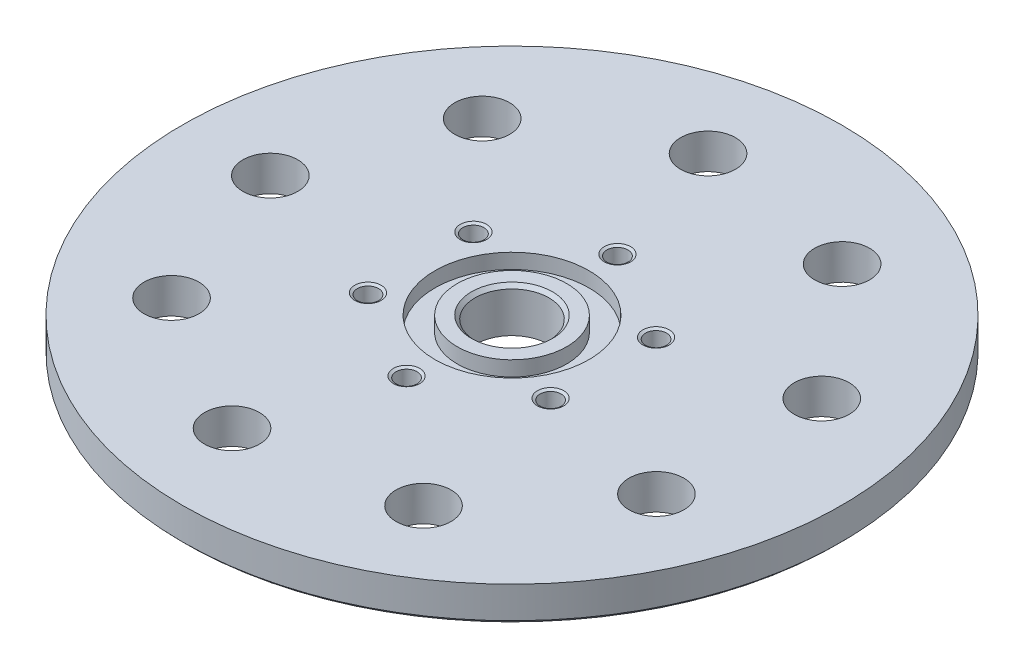
from build123d import *

# Parameters (mm, degrees)
SKETCH1_W               = 127
SKETCH1_H               = 127
BOSS_EXTRUDE1_DEPTH     = 5.08
CUT_EXTRUDE1_REACH      = 91.946
SKETCH2_R               = 5.3467
SKETCH4_R               = 11.1379
SKETCH4_R_2             = 7.9121
CUT_EXTRUDE3_DEPTH      = 2.159
CUT_EXTRUDE5_REACH      = 91.946
SKETCH6_R               = 3.96875
CIRPATTERN2_COUNT       = 9
CUT_EXTRUDE6_REACH      = 91.946
SKETCH7_R               = 3.175
SKETCH9_R               = 19.05
SKETCH9_R_2             = 5.3467
BOSS_EXTRUDE2_DEPTH     = 1.27
CUT_EXTRUDE7_DEPTH      = 91.02678768
CUT_EXTRUDE7_DEPTH_BACK = 91.02678768
SKETCH10_W              = 168.716053106
SKETCH10_H              = 169.87414825
SKETCH10_R              = 47.625
SKETCH16_R              = 19.05
SKETCH16_R_2            = 10.9855
BOSS_EXTRUDE3_DEPTH     = 0.762
CHAMFER1_SIZE           = 0.508
CIRPATTERN3_COUNT       = 6


with BuildPart() as part:
    # Sketch1 → Boss-Extrude1 (new body)
    with BuildSketch(Plane(origin=(0, 0, 0), x_dir=(1, 0, 0), z_dir=(0, 1, 0))):
        Rectangle(SKETCH1_W, SKETCH1_H)
    extrude(amount=BOSS_EXTRUDE1_DEPTH)

    # Sketch2 → Cut-Extrude1 (cut, up to next)
    with BuildSketch(Plane(origin=(0, 5.08, 0), x_dir=(1, 0, 0), z_dir=(0, 1, 0)), mode=Mode.PRIVATE) as cut_extrude1_sk1:
        Circle(SKETCH2_R)
    cut_extrude1_tool1 = extrude(cut_extrude1_sk1.sketch, amount=-CUT_EXTRUDE1_REACH, mode=Mode.PRIVATE) & part.part
    add(cut_extrude1_tool1.solids().sort_by_distance((0, 5.08, 0))[0], mode=Mode.SUBTRACT)

    # Sketch4 → Cut-Extrude3 (cut)
    with BuildSketch(Plane(origin=(0, 5.08, 0), x_dir=(1, 0, 0), z_dir=(0, 1, 0))):
        Circle(SKETCH4_R)
        Circle(SKETCH4_R_2, mode=Mode.SUBTRACT)
    extrude(amount=-CUT_EXTRUDE3_DEPTH, mode=Mode.SUBTRACT)

    # Sketch6 → Cut-Extrude5 (cut, up to next)
    with BuildSketch(Plane(origin=(0, 5.08, 0), x_dir=(1, 0, 0), z_dir=(0, 1, 0)), mode=Mode.PRIVATE) as cut_extrude5_sk1:
        with Locations((17.4625, -30.245937227)):
            Circle(SKETCH6_R)
    cut_extrude5_tool1 = extrude(cut_extrude5_sk1.sketch, amount=-CUT_EXTRUDE5_REACH, mode=Mode.PRIVATE) & part.part
    cut_extrude5 = cut_extrude5_tool1.solids().sort_by_distance((17.4625, 5.08, 30.245937))[0]
    add(cut_extrude5, mode=Mode.SUBTRACT)

    # CirPattern2: Cut-Extrude5 ×9 about axis
    cirpattern2_axis = Axis((0, 5.08, 0), (0, 1, 0))
    for i in range(1, CIRPATTERN2_COUNT):
        add(cut_extrude5.rotate(cirpattern2_axis, i * 360 / CIRPATTERN2_COUNT), mode=Mode.SUBTRACT)

    # Sketch7 → Cut-Extrude6 (cut, up to next)
    with BuildSketch(Plane(origin=(0, 5.08, 0), x_dir=(1, 0, 0), z_dir=(0, 1, 0)), mode=Mode.PRIVATE) as cut_extrude6_sk1:
        with Locations((57.15, 57.15)):
            Circle(SKETCH7_R)
    cut_extrude6_tool1 = extrude(cut_extrude6_sk1.sketch, amount=-CUT_EXTRUDE6_REACH, mode=Mode.PRIVATE) & part.part
    # Sketch7 → Cut-Extrude6 (cut, up to next)
    with BuildSketch(Plane(origin=(0, 5.08, 0), x_dir=(1, 0, 0), z_dir=(0, 1, 0)), mode=Mode.PRIVATE) as cut_extrude6_sk2:
        with Locations((57.15, -57.15)):
            Circle(SKETCH7_R)
    cut_extrude6_tool2 = extrude(cut_extrude6_sk2.sketch, amount=-CUT_EXTRUDE6_REACH, mode=Mode.PRIVATE) & part.part
    # Sketch7 → Cut-Extrude6 (cut, up to next)
    with BuildSketch(Plane(origin=(0, 5.08, 0), x_dir=(1, 0, 0), z_dir=(0, 1, 0)), mode=Mode.PRIVATE) as cut_extrude6_sk3:
        with Locations((-57.15, -57.15)):
            Circle(SKETCH7_R)
    cut_extrude6_tool3 = extrude(cut_extrude6_sk3.sketch, amount=-CUT_EXTRUDE6_REACH, mode=Mode.PRIVATE) & part.part
    # Sketch7 → Cut-Extrude6 (cut, up to next)
    with BuildSketch(Plane(origin=(0, 5.08, 0), x_dir=(1, 0, 0), z_dir=(0, 1, 0)), mode=Mode.PRIVATE) as cut_extrude6_sk4:
        with Locations((-57.15, 57.15)):
            Circle(SKETCH7_R)
    cut_extrude6_tool4 = extrude(cut_extrude6_sk4.sketch, amount=-CUT_EXTRUDE6_REACH, mode=Mode.PRIVATE) & part.part
    add(cut_extrude6_tool1.solids().sort_by_distance((57.15, 5.08, -57.15))[0], mode=Mode.SUBTRACT)
    add(cut_extrude6_tool2.solids().sort_by_distance((57.15, 5.08, 57.15))[0], mode=Mode.SUBTRACT)
    add(cut_extrude6_tool3.solids().sort_by_distance((-57.15, 5.08, 57.15))[0], mode=Mode.SUBTRACT)
    add(cut_extrude6_tool4.solids().sort_by_distance((-57.15, 5.08, -57.15))[0], mode=Mode.SUBTRACT)

    # Sketch9 → Boss-Extrude2 (add)
    with BuildSketch(Plane.XZ):
        Circle(SKETCH9_R)
        Circle(SKETCH9_R_2, mode=Mode.SUBTRACT)
    extrude(amount=BOSS_EXTRUDE2_DEPTH)

    # Sketch10 → Cut-Extrude7 (cut, two sides: drawn at the far end of the back side and taken through both)
    with BuildSketch(Plane(origin=(0, 5.08, 0), x_dir=(1, 0, 0), z_dir=(0, 1, 0)).offset(-CUT_EXTRUDE7_DEPTH_BACK)):
        Rectangle(SKETCH10_W, SKETCH10_H)
        Circle(SKETCH10_R, mode=Mode.SUBTRACT)
    extrude(amount=CUT_EXTRUDE7_DEPTH + CUT_EXTRUDE7_DEPTH_BACK, mode=Mode.SUBTRACT)

    # Sketch15 → Tapped Hole for _4-40 Helicoil3 (revolve, cut)
    with BuildSketch(Plane(origin=(0, 5.08, -15.24), x_dir=(0, 0, 1), z_dir=(1, 0, 0))):
        Polygon((0, 0), (0, 6.249711583), (1.524, 5.334), (1.524, 0.219970453), (1.905, 0), align=None)
    tapped_hole_for_4_40_helicoil3 = revolve(axis=Axis((0, 11.43, -15.24), (0, -1, 0)), mode=Mode.SUBTRACT)

    # Sketch16 → Boss-Extrude3 (add)
    with BuildSketch(Plane.XZ.offset(1.27)):
        Circle(SKETCH16_R)
        Circle(SKETCH16_R_2, mode=Mode.SUBTRACT)
    extrude(amount=BOSS_EXTRUDE3_DEPTH)

    # Chamfer1
    chamfer1_edges = [part.edges().sort_by_distance(p)[0] for p in [
        (-19.05, -2.032, 0),
        (-47.625, 0, 0),
        (-5.3467, 5.08, 0),
    ]]
    chamfer(chamfer1_edges, length=CHAMFER1_SIZE)

    # CirPattern3: Tapped Hole for _4-40 Helicoil3 ×6 about axis
    cirpattern3_axis = Axis((0, -1.27, 0), (0, 1, 0))
    for i in range(1, CIRPATTERN3_COUNT):
        add(tapped_hole_for_4_40_helicoil3.rotate(cirpattern3_axis, i * 360 / CIRPATTERN3_COUNT), mode=Mode.SUBTRACT)


solid = part.part
